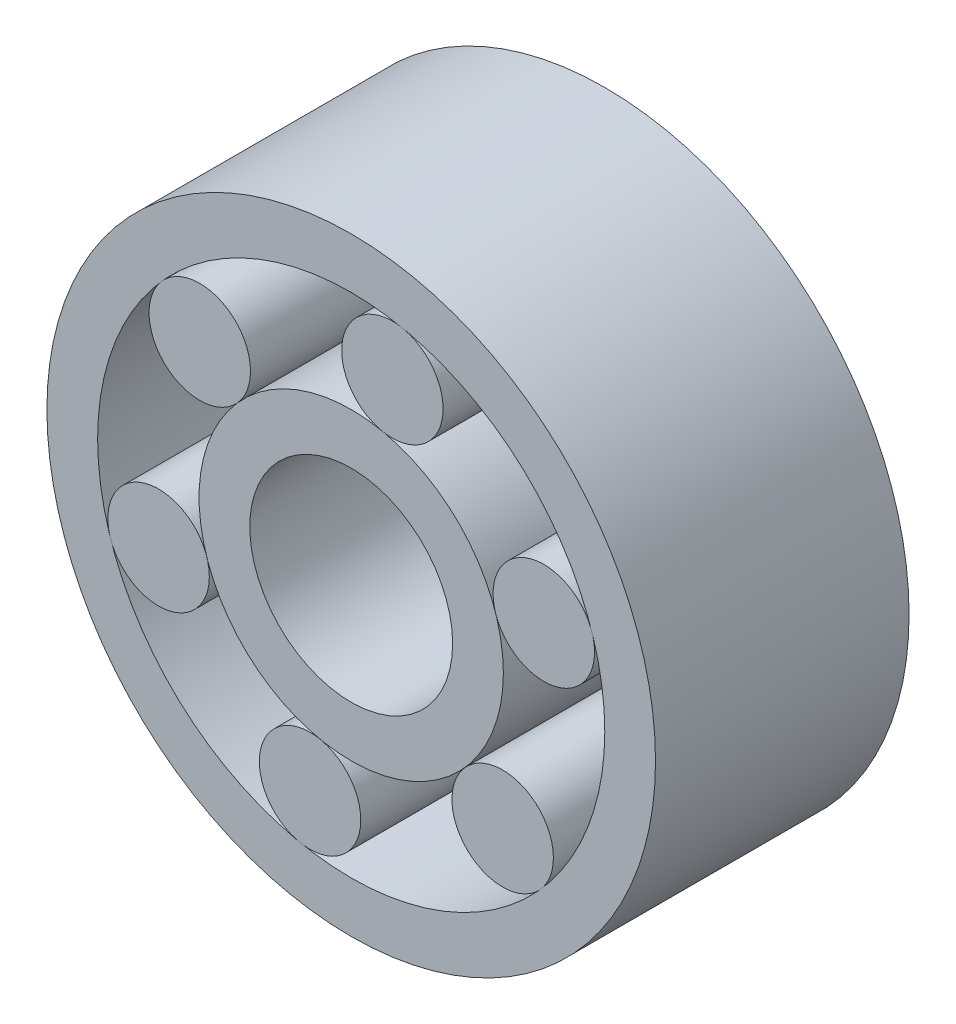
from build123d import *

# Parameters (mm, degrees)
SKETCH_1_R        = 3
SKETCH_1_R_2      = 2.5
EXTRUDE_1_DEPTH   = 2.5
SKETCH_1_R_3      = 1.5
SKETCH_1_R_4      = 1
EXTRUDE_1_2_DEPTH = 2.5
SKETCH_2_R        = 0.5
EXTRUDE_2_DEPTH   = 2.5
EXTRUDE_2_2_DEPTH = 2.5
EXTRUDE_2_3_DEPTH = 2.5
EXTRUDE_2_4_DEPTH = 2.5
EXTRUDE_2_5_DEPTH = 2.5
EXTRUDE_2_6_DEPTH = 2.5


with BuildPart() as part:
    # 草图1 → 凸台-拉伸1 (new body)
    with BuildSketch(Plane.XY):
        Circle(SKETCH_1_R)
        Circle(SKETCH_1_R_2, mode=Mode.SUBTRACT)
    extrude(amount=EXTRUDE_1_DEPTH)


with BuildPart() as body_2:
    # 草图1 → Extrude 1 2 (new body)
    with BuildSketch(Plane.XY):
        Circle(SKETCH_1_R_3)
        Circle(SKETCH_1_R_4, mode=Mode.SUBTRACT)
    extrude(amount=EXTRUDE_1_2_DEPTH)


with BuildPart() as body_3:
    # 草图2 → 凸台-拉伸2 (new body)
    with BuildSketch(Plane.XY):
        with Locations((-1.493093999, 1.330665363)):
            Circle(SKETCH_2_R)
    extrude(amount=EXTRUDE_2_DEPTH)


with BuildPart() as body_4:
    # 草图2 → Extrude 2 2 (new body)
    with BuildSketch(Plane.XY):
        with Locations((0.405843009, 1.958390015)):
            Circle(SKETCH_2_R)
    extrude(amount=EXTRUDE_2_2_DEPTH)


with BuildPart() as body_5:
    # 草图2 → Extrude 2 3 (new body)
    with BuildSketch(Plane.XY):
        with Locations((1.898937008, 0.627724652)):
            Circle(SKETCH_2_R)
    extrude(amount=EXTRUDE_2_3_DEPTH)


with BuildPart() as body_6:
    # 草图2 → Extrude 2 4 (new body)
    with BuildSketch(Plane.XY):
        with Locations((1.493093999, -1.330665363)):
            Circle(SKETCH_2_R)
    extrude(amount=EXTRUDE_2_4_DEPTH)


with BuildPart() as body_7:
    # 草图2 → Extrude 2 5 (new body)
    with BuildSketch(Plane.XY):
        with Locations((-0.405843009, -1.958390015)):
            Circle(SKETCH_2_R)
    extrude(amount=EXTRUDE_2_5_DEPTH)


with BuildPart() as body_8:
    # 草图2 → Extrude 2 6 (new body)
    with BuildSketch(Plane.XY):
        with Locations((-1.898937008, -0.627724652)):
            Circle(SKETCH_2_R)
    extrude(amount=EXTRUDE_2_6_DEPTH)


solid = Compound([part.part, body_2.part, body_3.part, body_4.part, body_5.part, body_6.part, body_7.part, body_8.part])
